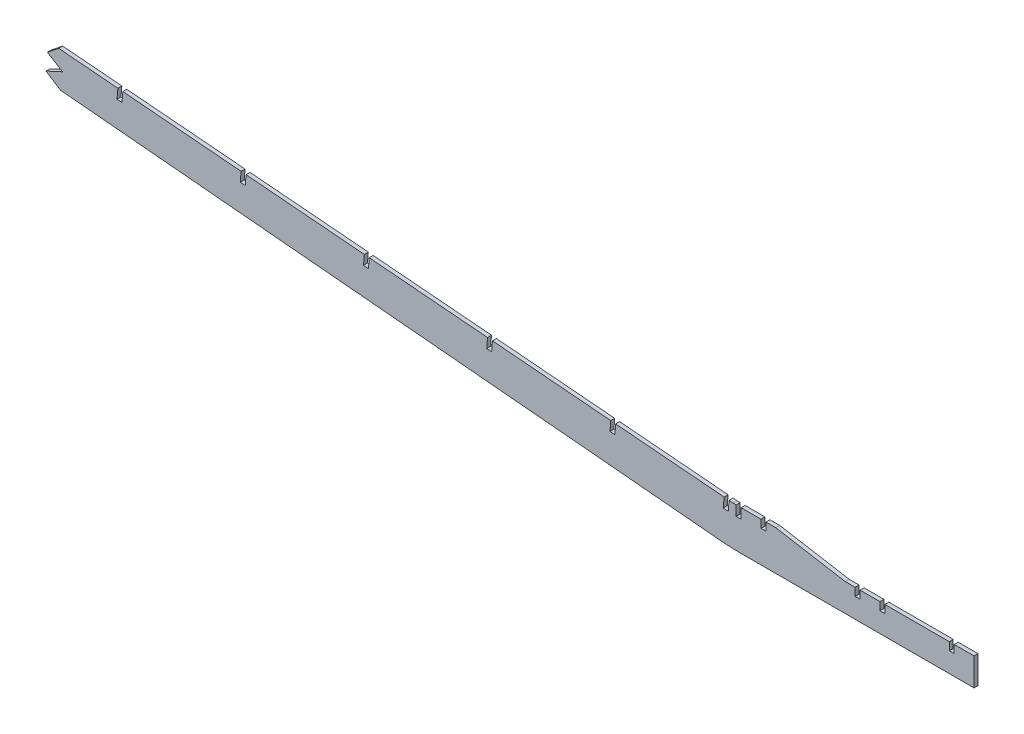
from build123d import *

# Parameters (mm, degrees)
BOSS_EXTRUDE1_DEPTH     = 2.54
CUT_EXTRUDE1_DEPTH      = 1
CUT_EXTRUDE1_DEPTH_BACK = 3.54
CUT_EXTRUDE2_DEPTH      = 7.62


with BuildPart() as part:
    # Sketch1 → Boss-Extrude1 (new body)
    with BuildSketch(Plane.XY):
        Polygon((-945.957227657, 86.137779906), (-945.969713578, 86.1172966), (-949.121092485, 86.403457059), (-949.65244679, 80.075727402), (-9.887238192, -5.25964904), (-6.723373364, -5.525326193), (0, -5.833733414), (152.4, -5.833733414), (152.4, 11.946266586), (139.7, 11.946266586), (139.7, 6.866266586), (136.525, 6.866266586), (136.525, 11.946266586), (95.25, 11.946266586), (95.25, 6.866266586), (92.075, 6.866266586), (92.075, 11.946266586), (79.375, 11.946266586), (79.375, 6.866266586), (76.2, 6.866266586), (76.2, 11.946266586), (69.85, 11.946266586), (25.4, 19.566266586), (19.05, 19.566266586), (19.05, 14.486266586), (15.875, 14.486266586), (15.875, 19.566266586), (3.175, 19.566266586), (3.175, 13.216266586), (0, 13.216266586), (0, 19.566266586), (-1.98607431, 19.566266586), (-4.597956143, 19.785592432), (-5.129310448, 13.457862776), (-8.293175277, 13.723539928), (-7.761820971, 20.051269584), (-944.89858306, 98.744842179), align=None)
    extrude(amount=BOSS_EXTRUDE1_DEPTH)

    # Sketch2 → Cut-Extrude1 (cut, two sides)
    with BuildSketch(Plane.XY.offset(2.54)) as cut_extrude1_sk:
        Polygon((-867.4716203, 85.879017088), (-866.940953695, 92.198557139), (-870.104818523, 92.464234292), (-870.635482595, 86.144724398), align=None)
        Polygon((-788.501617399, 79.246962625), (-787.970887585, 85.567255411), (-791.134752413, 85.832932563), (-791.665479694, 79.512669935), align=None)
        Polygon((-709.531614498, 72.614908162), (-709.000821475, 78.935953682), (-712.164686303, 79.201630835), (-712.695476794, 72.880615473), align=None)
        Polygon((-630.561611597, 65.9828537), (-630.030755365, 72.304651954), (-633.194620194, 72.570329107), (-633.725473893, 66.24856101), align=None)
        Polygon((-551.591608696, 59.350799237), (-551.060689256, 65.673350226), (-554.224554084, 65.939027378), (-554.755470992, 59.616506547), align=None)
        Polygon((-472.621605795, 52.718744774), (-472.090623146, 59.042048497), (-475.254487974, 59.30772565), (-475.785468091, 52.984452084), align=None)
        Polygon((-393.651602894, 46.086690311), (-393.120557036, 52.410746769), (-396.284421864, 52.676423921), (-396.81546519, 46.352397622), align=None)
        Polygon((-314.681599993, 39.454635849), (-314.150490926, 45.77944504), (-317.314355754, 46.045122193), (-317.845462289, 39.720343159), align=None)
        Polygon((-235.711597092, 32.822581386), (-235.180424816, 39.148143312), (-238.344289645, 39.413820465), (-238.875459388, 33.088288696), align=None)
        Polygon((-156.741594191, 26.190526923), (-156.210358707, 32.516841584), (-159.374223535, 32.782518736), (-159.905456487, 26.456234233), align=None)
        Polygon((-77.240292597, 25.885539855), (-80.404157425, 26.151217008), (-80.935453586, 19.824179771), (-77.77159129, 19.55847246), align=None)
    extrude(amount=CUT_EXTRUDE1_DEPTH, mode=Mode.SUBTRACT)
    extrude(cut_extrude1_sk.sketch, amount=-CUT_EXTRUDE1_DEPTH_BACK, mode=Mode.SUBTRACT)

    # Sketch3 → Cut-Extrude2 (cut)
    with BuildSketch(Plane.XY.offset(2.54)):
        Polygon((-434.187522505, 55.859236209), (-441.444486836, 50.074133547), (-431.803024179, 44.022577198), (-442.349656028, 39.171455119), (-433.014300591, 33.162402364), (-1000.074058288, -11.780320021), (-979.22273749, 133.880780984), align=None)
    extrude(amount=-CUT_EXTRUDE2_DEPTH, mode=Mode.SUBTRACT)


solid = part.part
